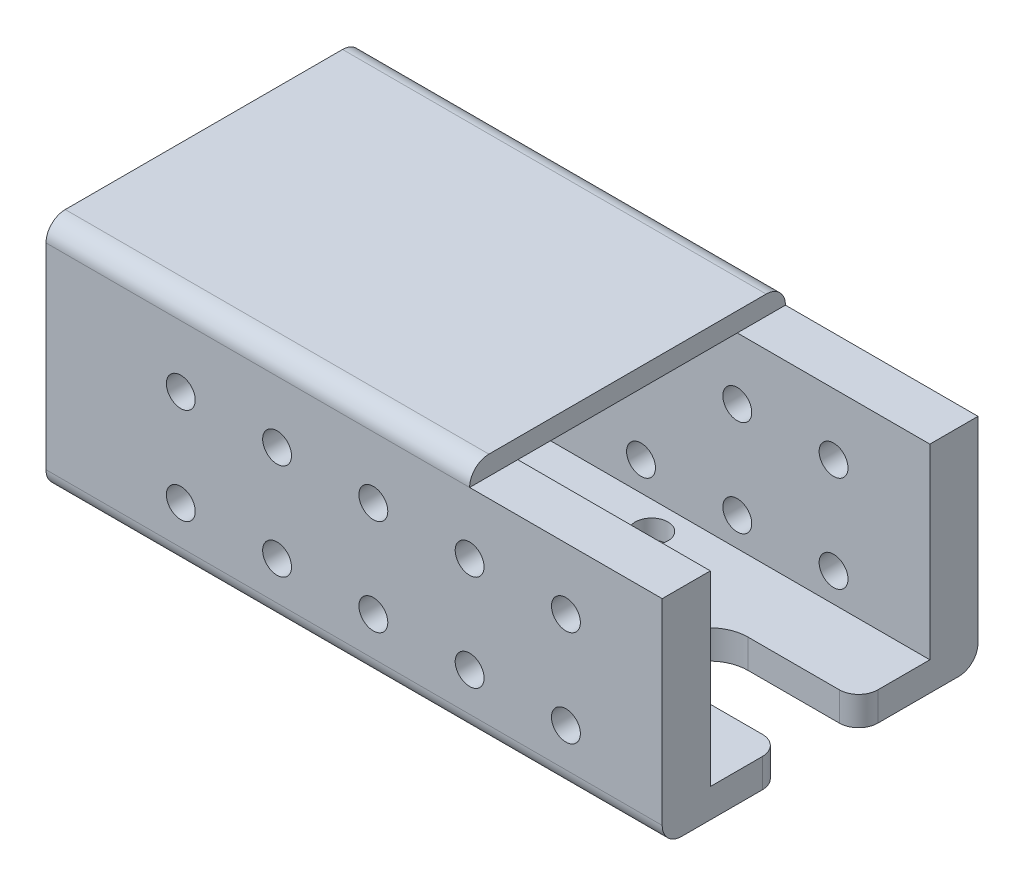
from build123d import *

# Parameters (mm, degrees)
ESQUISSE1_W                                       = 60
ESQUISSE1_H                                       = 22.8
BOSS_EXTRU_1_DEPTH                                = 1.5
ESQUISSE2_W                                       = 60
ESQUISSE2_H                                       = 5
BOSS_EXTRU_2_DEPTH                                = 10
ESQUISSE7_W                                       = 60
ESQUISSE7_H                                       = 22.4
BOSS_EXTRU_3_DEPTH                                = 5
DIAM_TRE_DU_PER_AGE_3_0_3_2_AT_2_COUNT            = 2
DIAM_TRE_DU_PER_AGE_3_0_3_2_AT_2_PITCH            = 10
DIAM_TRE_DU_PER_AGE_3_0_3_2_AT_3_COUNT            = 2
DIAM_TRE_DU_PER_AGE_3_0_3_2_AT_3_PITCH            = 20
DIAM_TRE_DU_PER_AGE_3_0_3_2_AT_4_COUNT            = 2
DIAM_TRE_DU_PER_AGE_3_0_3_2_AT_4_PITCH            = 30
DIAM_TRE_DU_PER_AGE_3_0_3_2_AT_5_COUNT            = 2
DIAM_TRE_DU_PER_AGE_3_0_3_2_AT_5_PITCH            = 40
R_P_TITION_LIN_AIRE2_COUNT                        = 2
R_P_TITION_LIN_AIRE2_PITCH                        = 10
CHAMBRAGE_POUR_VIS_SIX_PANS_CREUX_M31_D           = 3.4
CHAMBRAGE_POUR_VIS_SIX_PANS_CREUX_M31_DEPTH       = 13
CHAMBRAGE_POUR_VIS_SIX_PANS_CREUX_M31_CBORE_D     = 6.5
CHAMBRAGE_POUR_VIS_SIX_PANS_CREUX_M31_CBORE_DEPTH = 1
CHAMBRAGE_POUR_VIS_SIX_PANS_CREUX_M31_TIP         = 1.021463052
R_P_TITION_LIN_AIRE1_COUNT                        = 3
R_P_TITION_LIN_AIRE1_PITCH                        = 10
ESQUISSE10_W                                      = 40
ESQUISSE10_H                                      = 32.8
BOSS_EXTRU_4_DEPTH                                = 2
ESQUISSE11_W                                      = 20
ESQUISSE11_H                                      = 10
ENL_V_MAT_EXTRU_1_DEPTH                           = 17.4
ENL_V_MAT_EXTRU_1_DEPTH_BACK                      = 17.4
ESQUISSE12_R                                      = 4
ESQUISSE12_W                                      = 11.5
ESQUISSE12_H                                      = 8
ENL_V_MAT_EXTRU_2_DEPTH                           = 23.9
ENL_V_MAT_EXTRU_2_DEPTH_BACK                      = 12.5
BOSS_EXTRU_5_DEPTH                                = 4
ESQUISSE14_W                                      = 2
ESQUISSE14_H                                      = 8
ENL_V_MAT_EXTRU_3_DEPTH                           = 1
ENL_V_MAT_EXTRU_3_DEPTH_BACK                      = 65
CONG_2_R                                          = 2
ESQUISSE15_W                                      = 14.8
ESQUISSE15_H                                      = 1.5
ENL_V_MAT_EXTRU_4_DEPTH                           = 5
ENL_V_MAT_EXTRU_4_DEPTH_BACK                      = 25
CONG_3_R                                          = 0.5


with BuildPart() as part:
    # Esquisse1 → Boss.-Extru.1 (new body, symmetric)
    with BuildSketch(Plane(origin=(0, 0, 0), x_dir=(1, 0, 0), z_dir=(0, 1, 0))):
        Rectangle(ESQUISSE1_W, ESQUISSE1_H)
    extrude(amount=BOSS_EXTRU_1_DEPTH, both=True)

    # Esquisse2 → Boss.-Extru.2 (add)
    with BuildSketch(Plane.XZ.offset(1.5)):
        Rectangle(ESQUISSE2_W, ESQUISSE2_H)
    extrude(amount=BOSS_EXTRU_2_DEPTH)

    # Esquisse7 → Boss.-Extru.3 (add)
    with BuildSketch(Plane(origin=(0, 0, -11.4), x_dir=(-1, 0, 0), z_dir=(0, 0, -1))):
        with Locations((0, 9.7)):
            Rectangle(ESQUISSE7_W, ESQUISSE7_H)
    boss_extru_3 = extrude(amount=BOSS_EXTRU_3_DEPTH)

    # Esquisse9 → Diamètre du perçage Ø3.0 (3)2 (revolve, cut)
    with BuildSketch(Plane(origin=(20, 4.5, -16.4), x_dir=(0, 1, 0), z_dir=(1, 0, 0))):
        Polygon((0, 0), (0, 13.901290929), (1.5, 13), (1.5, 0), align=None)
    diam_tre_du_per_age_3_0_3_2 = revolve(axis=Axis((20, 4.5, -22.75), (0, 0, 1)), mode=Mode.SUBTRACT)

    # Diamètre du perçage Ø3.0 (3)2 at 2: Diamètre du perçage Ø3.0 (3)2 ×2
    with Locations(*[(-i * DIAM_TRE_DU_PER_AGE_3_0_3_2_AT_2_PITCH, 0, 0) for i in range(1, DIAM_TRE_DU_PER_AGE_3_0_3_2_AT_2_COUNT)]):
        add(diam_tre_du_per_age_3_0_3_2, mode=Mode.SUBTRACT)

    # Diamètre du perçage Ø3.0 (3)2 at 3: Diamètre du perçage Ø3.0 (3)2 ×2
    with Locations(*[(-i * DIAM_TRE_DU_PER_AGE_3_0_3_2_AT_3_PITCH, 0, 0) for i in range(1, DIAM_TRE_DU_PER_AGE_3_0_3_2_AT_3_COUNT)]):
        add(diam_tre_du_per_age_3_0_3_2, mode=Mode.SUBTRACT)

    # Diamètre du perçage Ø3.0 (3)2 at 4: Diamètre du perçage Ø3.0 (3)2 ×2
    with Locations(*[(-i * DIAM_TRE_DU_PER_AGE_3_0_3_2_AT_4_PITCH, 0, 0) for i in range(1, DIAM_TRE_DU_PER_AGE_3_0_3_2_AT_4_COUNT)]):
        add(diam_tre_du_per_age_3_0_3_2, mode=Mode.SUBTRACT)

    # Diamètre du perçage Ø3.0 (3)2 at 5: Diamètre du perçage Ø3.0 (3)2 ×2
    with Locations(*[(-i * DIAM_TRE_DU_PER_AGE_3_0_3_2_AT_5_PITCH, 0, 0) for i in range(1, DIAM_TRE_DU_PER_AGE_3_0_3_2_AT_5_COUNT)]):
        add(diam_tre_du_per_age_3_0_3_2, mode=Mode.SUBTRACT)

    # Répétition linéaire2: Diamètre du perçage Ø3.0 (3)2 ×2
    with Locations(*[(0, i * R_P_TITION_LIN_AIRE2_PITCH, 0) for i in range(1, R_P_TITION_LIN_AIRE2_COUNT)]):
        add(diam_tre_du_per_age_3_0_3_2, mode=Mode.SUBTRACT)

    # Répétition linéaire2 copy 1 sketch → Répétition linéaire2 copy 1 (revolve, cut)
    with BuildSketch(Plane(origin=(10, 14.5, -16.4), x_dir=(0, 1, 0), z_dir=(1, 0, 0))):
        Polygon((0, 0), (0, 13.901290929), (1.5, 13), (1.5, 0), align=None)
    revolve(axis=Axis((10, 14.5, -22.75), (0, 0, 1)), mode=Mode.SUBTRACT)

    # Répétition linéaire2 copy 2 sketch → Répétition linéaire2 copy 2 (revolve, cut)
    with BuildSketch(Plane(origin=(0, 14.5, -16.4), x_dir=(0, 1, 0), z_dir=(1, 0, 0))):
        Polygon((0, 0), (0, 13.901290929), (1.5, 13), (1.5, 0), align=None)
    revolve(axis=Axis((0, 14.5, -22.75), (0, 0, 1)), mode=Mode.SUBTRACT)

    # Répétition linéaire2 copy 3 sketch → Répétition linéaire2 copy 3 (revolve, cut)
    with BuildSketch(Plane(origin=(-10, 14.5, -16.4), x_dir=(0, 1, 0), z_dir=(1, 0, 0))):
        Polygon((0, 0), (0, 13.901290929), (1.5, 13), (1.5, 0), align=None)
    revolve(axis=Axis((-10, 14.5, -22.75), (0, 0, 1)), mode=Mode.SUBTRACT)

    # Répétition linéaire2 copy 4 sketch → Répétition linéaire2 copy 4 (revolve, cut)
    with BuildSketch(Plane(origin=(-20, 14.5, -16.4), x_dir=(0, 1, 0), z_dir=(1, 0, 0))):
        Polygon((0, 0), (0, 13.901290929), (1.5, 13), (1.5, 0), align=None)
    revolve(axis=Axis((-20, 14.5, -22.75), (0, 0, 1)), mode=Mode.SUBTRACT)

    # Symétrie1: Boss.-Extru.3, Diamètre du perçage Ø3.0 (3)2 across plane
    add(boss_extru_3.mirror(Plane.XY))
    add(diam_tre_du_per_age_3_0_3_2.mirror(Plane.XY), mode=Mode.SUBTRACT)

    # Symétrie1 copy 1 sketch → Symétrie1 copy 1 (revolve, cut)
    with BuildSketch(Plane(origin=(20, 14.5, 16.4), x_dir=(0, 1, 0), z_dir=(1, 0, 0))):
        Polygon((0, 0), (0, -13.901290929), (1.5, -13), (1.5, 0), align=None)
    revolve(axis=Axis((20, 14.5, 22.75), (0, 0, 1)), mode=Mode.SUBTRACT)

    # Symétrie1 copy 2 sketch → Symétrie1 copy 2 (revolve, cut)
    with BuildSketch(Plane(origin=(10, 14.5, 16.4), x_dir=(0, 1, 0), z_dir=(1, 0, 0))):
        Polygon((0, 0), (0, -13.901290929), (1.5, -13), (1.5, 0), align=None)
    revolve(axis=Axis((10, 14.5, 22.75), (0, 0, 1)), mode=Mode.SUBTRACT)

    # Symétrie1 copy 3 sketch → Symétrie1 copy 3 (revolve, cut)
    with BuildSketch(Plane(origin=(0, 14.5, 16.4), x_dir=(0, 1, 0), z_dir=(1, 0, 0))):
        Polygon((0, 0), (0, -13.901290929), (1.5, -13), (1.5, 0), align=None)
    revolve(axis=Axis((0, 14.5, 22.75), (0, 0, 1)), mode=Mode.SUBTRACT)

    # Symétrie1 copy 4 sketch → Symétrie1 copy 4 (revolve, cut)
    with BuildSketch(Plane(origin=(-10, 14.5, 16.4), x_dir=(0, 1, 0), z_dir=(1, 0, 0))):
        Polygon((0, 0), (0, -13.901290929), (1.5, -13), (1.5, 0), align=None)
    revolve(axis=Axis((-10, 14.5, 22.75), (0, 0, 1)), mode=Mode.SUBTRACT)

    # Symétrie1 copy 5 sketch → Symétrie1 copy 5 (revolve, cut)
    with BuildSketch(Plane(origin=(-20, 14.5, 16.4), x_dir=(0, 1, 0), z_dir=(1, 0, 0))):
        Polygon((0, 0), (0, -13.901290929), (1.5, -13), (1.5, 0), align=None)
    revolve(axis=Axis((-20, 14.5, 22.75), (0, 0, 1)), mode=Mode.SUBTRACT)

    # Symétrie1 copy 6 sketch → Symétrie1 copy 6 (revolve, cut)
    with BuildSketch(Plane(origin=(10, 4.5, 16.4), x_dir=(0, 1, 0), z_dir=(1, 0, 0))):
        Polygon((0, 0), (0, -13.901290929), (1.5, -13), (1.5, 0), align=None)
    revolve(axis=Axis((10, 4.5, 22.75), (0, 0, 1)), mode=Mode.SUBTRACT)

    # Symétrie1 copy 7 sketch → Symétrie1 copy 7 (revolve, cut)
    with BuildSketch(Plane(origin=(0, 4.5, 16.4), x_dir=(0, 1, 0), z_dir=(1, 0, 0))):
        Polygon((0, 0), (0, -13.901290929), (1.5, -13), (1.5, 0), align=None)
    revolve(axis=Axis((0, 4.5, 22.75), (0, 0, 1)), mode=Mode.SUBTRACT)

    # Symétrie1 copy 8 sketch → Symétrie1 copy 8 (revolve, cut)
    with BuildSketch(Plane(origin=(-10, 4.5, 16.4), x_dir=(0, 1, 0), z_dir=(1, 0, 0))):
        Polygon((0, 0), (0, -13.901290929), (1.5, -13), (1.5, 0), align=None)
    revolve(axis=Axis((-10, 4.5, 22.75), (0, 0, 1)), mode=Mode.SUBTRACT)

    # Symétrie1 copy 9 sketch → Symétrie1 copy 9 (revolve, cut)
    with BuildSketch(Plane(origin=(-20, 4.5, 16.4), x_dir=(0, 1, 0), z_dir=(1, 0, 0))):
        Polygon((0, 0), (0, -13.901290929), (1.5, -13), (1.5, 0), align=None)
    revolve(axis=Axis((-20, 4.5, 22.75), (0, 0, 1)), mode=Mode.SUBTRACT)

    # Esquisse4 → Diamètre du perçage Ø3.0 (3)1 (revolve, cut)
    with BuildSketch(Plane(origin=(-20, -6.5, 2.5), x_dir=(0, -1, 0), z_dir=(1, 0, 0))):
        Polygon((0, 0), (0, 13.901290929), (1.5, 13), (1.5, 0), align=None)
    diam_tre_du_per_age_3_0_3_1 = revolve(axis=Axis((-20, -6.5, 8.85), (0, 0, -1)), mode=Mode.SUBTRACT)

    # Chambrage pour vis à six pans creux M31
    with Locations(Plane(origin=(0, -1.5, 0), x_dir=(-1, 0, 0), z_dir=(0, -1, 0))):
        with Locations((-4, 8.5), (-4, -8.5)):
            CounterBoreHole(CHAMBRAGE_POUR_VIS_SIX_PANS_CREUX_M31_D / 2, CHAMBRAGE_POUR_VIS_SIX_PANS_CREUX_M31_CBORE_D / 2, CHAMBRAGE_POUR_VIS_SIX_PANS_CREUX_M31_CBORE_DEPTH, depth=CHAMBRAGE_POUR_VIS_SIX_PANS_CREUX_M31_DEPTH)
            with Locations((0, 0, -(CHAMBRAGE_POUR_VIS_SIX_PANS_CREUX_M31_DEPTH + CHAMBRAGE_POUR_VIS_SIX_PANS_CREUX_M31_TIP / 2))):  # 118° drill point
                Cone(0, CHAMBRAGE_POUR_VIS_SIX_PANS_CREUX_M31_D / 2, CHAMBRAGE_POUR_VIS_SIX_PANS_CREUX_M31_TIP, mode=Mode.SUBTRACT)

    # Répétition linéaire1: Diamètre du perçage Ø3.0 (3)1 ×3
    with Locations(*[(i * R_P_TITION_LIN_AIRE1_PITCH, 0, 0) for i in range(1, R_P_TITION_LIN_AIRE1_COUNT)]):
        add(diam_tre_du_per_age_3_0_3_1, mode=Mode.SUBTRACT)

    # Esquisse10 → Boss.-Extru.4 (add)
    with BuildSketch(Plane(origin=(0, 20.9, 0), x_dir=(1, 0, 0), z_dir=(0, 1, 0))):
        with Locations((-10, 0)):
            Rectangle(ESQUISSE10_W, ESQUISSE10_H)
    extrude(amount=BOSS_EXTRU_4_DEPTH)

    # Esquisse11 → Enlèv. mat.-Extru.1 (cut, two sides)
    with BuildSketch(Plane.XY) as enl_v_mat_extru_1_sk:
        with Locations((20, -6.5)):
            Rectangle(ESQUISSE11_W, ESQUISSE11_H)
    extrude(amount=ENL_V_MAT_EXTRU_1_DEPTH, mode=Mode.SUBTRACT)
    extrude(enl_v_mat_extru_1_sk.sketch, amount=-ENL_V_MAT_EXTRU_1_DEPTH_BACK, mode=Mode.SUBTRACT)

    # Esquisse12 → Enlèv. mat.-Extru.2 (cut, two sides)
    with BuildSketch(Plane(origin=(0, 0, 0), x_dir=(1, 0, 0), z_dir=(0, 1, 0))) as enl_v_mat_extru_2_sk:
        with Locations((18.5, 0)):
            Circle(ESQUISSE12_R)
        with Locations((24.25, 0)):
            Rectangle(ESQUISSE12_W, ESQUISSE12_H)
    extrude(amount=ENL_V_MAT_EXTRU_2_DEPTH, mode=Mode.SUBTRACT)
    extrude(enl_v_mat_extru_2_sk.sketch, amount=-ENL_V_MAT_EXTRU_2_DEPTH_BACK, mode=Mode.SUBTRACT)

    # Esquisse13 → Boss.-Extru.5 (add)
    with BuildSketch(Plane.ZY.offset(30)):
        Polygon((16.4, 22.9), (-16.4, 22.9), (-16.4, 8.9), (-11.4, 8.9), (-11.4, 20.9), (11.4, 20.9), (11.4, 8.9), (16.4, 8.9), align=None)
        Polygon((-11.4, 20.9), (-11.4, 8.9), (11.359705281, 8.9), (11.4, 8.9), (11.4, 20.9), align=None)
        Polygon((-11.4, 8.9), (-16.4, 8.9), (-16.4, -1.5), (-2.5, -1.5), (-2.5, -11.5), (2.5, -11.5), (2.5, -1.5), (16.4, -1.5), (16.4, 8.9), (11.4, 8.9), (11.4, 1.5), (-11.4, 1.5), align=None)
    extrude(amount=BOSS_EXTRU_5_DEPTH)

    # Esquisse14 → Enlèv. mat.-Extru.3 (cut, two sides)
    with BuildSketch(Plane.ZY.offset(34)) as enl_v_mat_extru_3_sk:
        with Locations((7, 16.010631071)):
            Rectangle(ESQUISSE14_W, ESQUISSE14_H)
        with Locations((-7, 16.010631071)):
            Rectangle(ESQUISSE14_W, ESQUISSE14_H)
    extrude(amount=ENL_V_MAT_EXTRU_3_DEPTH, mode=Mode.SUBTRACT)
    extrude(enl_v_mat_extru_3_sk.sketch, amount=-ENL_V_MAT_EXTRU_3_DEPTH_BACK, mode=Mode.SUBTRACT)

    # Congé2
    cong_2_edges = [part.edges().sort_by_distance(p)[0] for p in [
        (-12, -1.5, -2.5),
        (-12, 22.9, 16.4),
        (-12, 22.9, -16.4),
        (-12, -1.5, 2.5),
        (10, -1.5, 0),
        (30, 0, -4),
        (30, 0, 4),
        (-2, -1.5, -16.4),
        (-2, -1.5, 16.4),
    ]]
    fillet(cong_2_edges, radius=CONG_2_R)

    # Esquisse15 → Enlèv. mat.-Extru.4 (cut, two sides)
    with BuildSketch(Plane.ZY.offset(30)) as enl_v_mat_extru_4_sk:
        with Locations((0, 0.75)):
            Rectangle(ESQUISSE15_W, ESQUISSE15_H)
    extrude(amount=ENL_V_MAT_EXTRU_4_DEPTH, mode=Mode.SUBTRACT)
    extrude(enl_v_mat_extru_4_sk.sketch, amount=-ENL_V_MAT_EXTRU_4_DEPTH_BACK, mode=Mode.SUBTRACT)

    # Congé3
    cong_3_edges = [part.edges().sort_by_distance(p)[0] for p in [
        (-19.5, 1.5, -7.4),
        (-19.5, 0, -7.4),
        (-5, 0, 0),
        (-19.5, 0, 7.4),
        (-19.5, 1.5, 7.4),
        (-5, 1.5, 0),
    ]]
    fillet(cong_3_edges, radius=CONG_3_R)


solid = part.part
